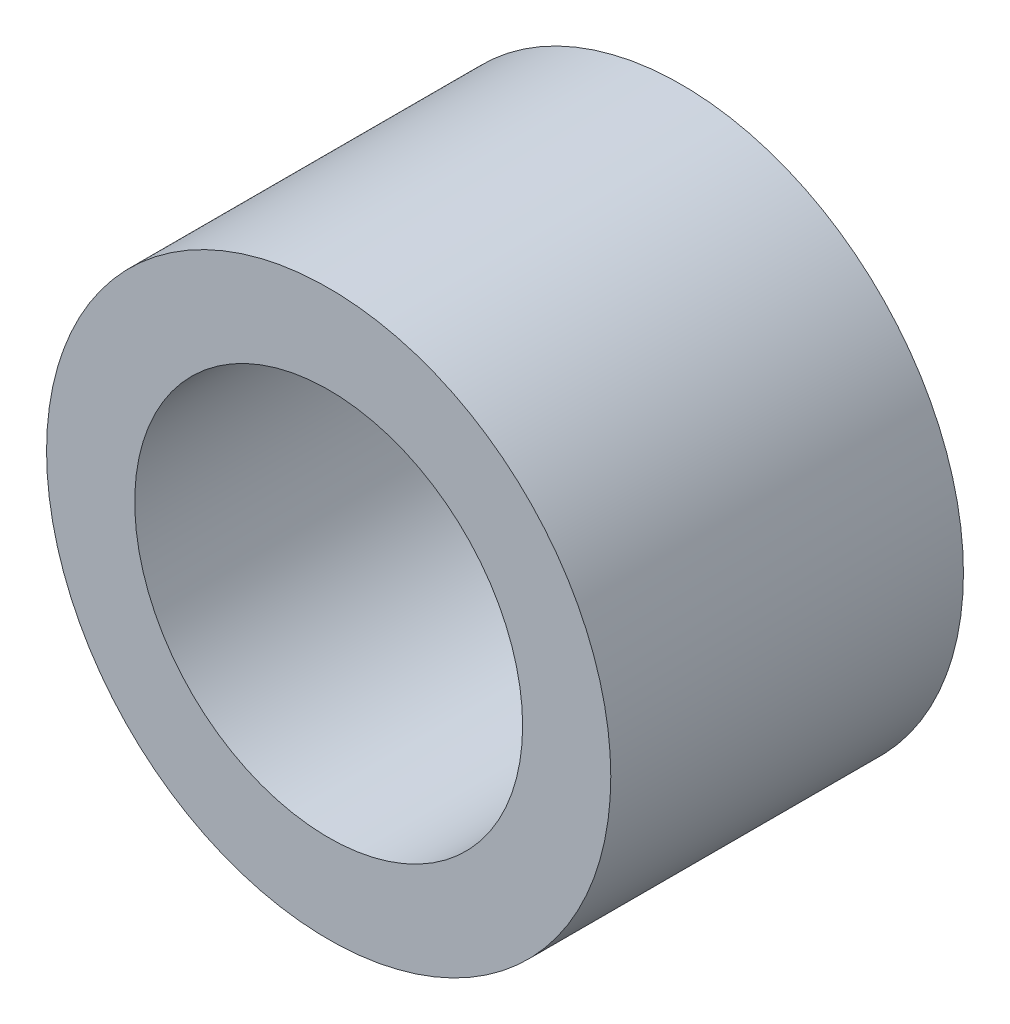
from build123d import *

# Parameters (mm, degrees)
SKETCH_1_R      = 4
SKETCH_1_R_2    = 2.75
EXTRUDE_1_DEPTH = 5


with BuildPart() as part:
    # ｽｹｯﾁ1 → ﾎﾞｽ - 押し出し1 (new body)
    with BuildSketch(Plane.XY):
        Circle(SKETCH_1_R)
        Circle(SKETCH_1_R_2, mode=Mode.SUBTRACT)
    extrude(amount=EXTRUDE_1_DEPTH)


solid = part.part
